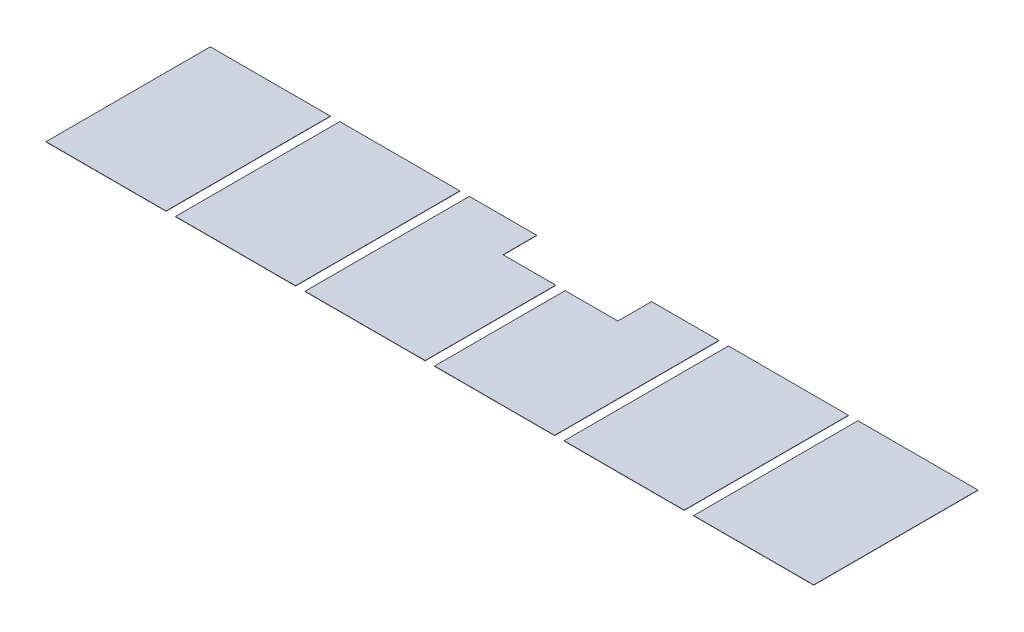
from build123d import *

# Parameters (mm, degrees)
SKETCH1_W             = 1447.8
SKETCH1_H             = 1981.2
BOSS_EXTRUDE3_DEPTH   = 3.175
BOSS_EXTRUDE3_2_DEPTH = 3.175
BOSS_EXTRUDE3_3_DEPTH = 3.175
BOSS_EXTRUDE3_4_DEPTH = 3.175
BOSS_EXTRUDE3_5_DEPTH = 3.175
BOSS_EXTRUDE3_6_DEPTH = 3.175


with BuildPart() as part:
    # Sketch1 → Boss-Extrude3 (new body)
    with BuildSketch(Plane(origin=(0, 40.64, 0), x_dir=(1, 0, 0), z_dir=(0, 1, 0))):
        with Locations((2349.5, 1054.1)):
            Rectangle(SKETCH1_W, SKETCH1_H)
    extrude(amount=BOSS_EXTRUDE3_DEPTH)


with BuildPart() as body_2:
    # Sketch1 → Boss-Extrude3 2 (new body)
    with BuildSketch(Plane(origin=(0, 40.64, 0), x_dir=(1, 0, 0), z_dir=(0, 1, 0))):
        with Locations((787.4, 1054.1)):
            Rectangle(SKETCH1_W, SKETCH1_H)
    extrude(amount=BOSS_EXTRUDE3_2_DEPTH)


with BuildPart() as body_3:
    # Sketch1 → Boss-Extrude3 3 (new body)
    with BuildSketch(Plane(origin=(0, 40.64, 0), x_dir=(1, 0, 0), z_dir=(0, 1, 0))):
        with Locations((8597.9, 1054.1)):
            Rectangle(SKETCH1_W, SKETCH1_H)
    extrude(amount=BOSS_EXTRUDE3_3_DEPTH)


with BuildPart() as body_4:
    # Sketch1 → Boss-Extrude3 4 (new body)
    with BuildSketch(Plane(origin=(0, 40.64, 0), x_dir=(1, 0, 0), z_dir=(0, 1, 0))):
        with Locations((7035.8, 1054.1)):
            Rectangle(SKETCH1_W, SKETCH1_H)
    extrude(amount=BOSS_EXTRUDE3_4_DEPTH)


with BuildPart() as body_5:
    # Sketch1 → Boss-Extrude3 5 (new body)
    with BuildSketch(Plane(origin=(0, 40.64, 0), x_dir=(1, 0, 0), z_dir=(0, 1, 0))):
        Polygon((6197.6, 2044.7), (5384.8, 2044.7), (5384.8, 1638.3), (4749.8, 1638.3), (4749.8, 63.5), (6197.6, 63.5), align=None)
    extrude(amount=BOSS_EXTRUDE3_5_DEPTH)


with BuildPart() as body_6:
    # Sketch1 → Boss-Extrude3 6 (new body)
    with BuildSketch(Plane(origin=(0, 40.64, 0), x_dir=(1, 0, 0), z_dir=(0, 1, 0))):
        Polygon((3187.7, 2044.7), (3187.7, 63.5), (4635.5, 63.5), (4635.5, 1638.3), (4000.5, 1638.3), (4000.5, 2044.7), align=None)
    extrude(amount=BOSS_EXTRUDE3_6_DEPTH)


solid = Compound([part.part, body_2.part, body_3.part, body_4.part, body_5.part, body_6.part])
